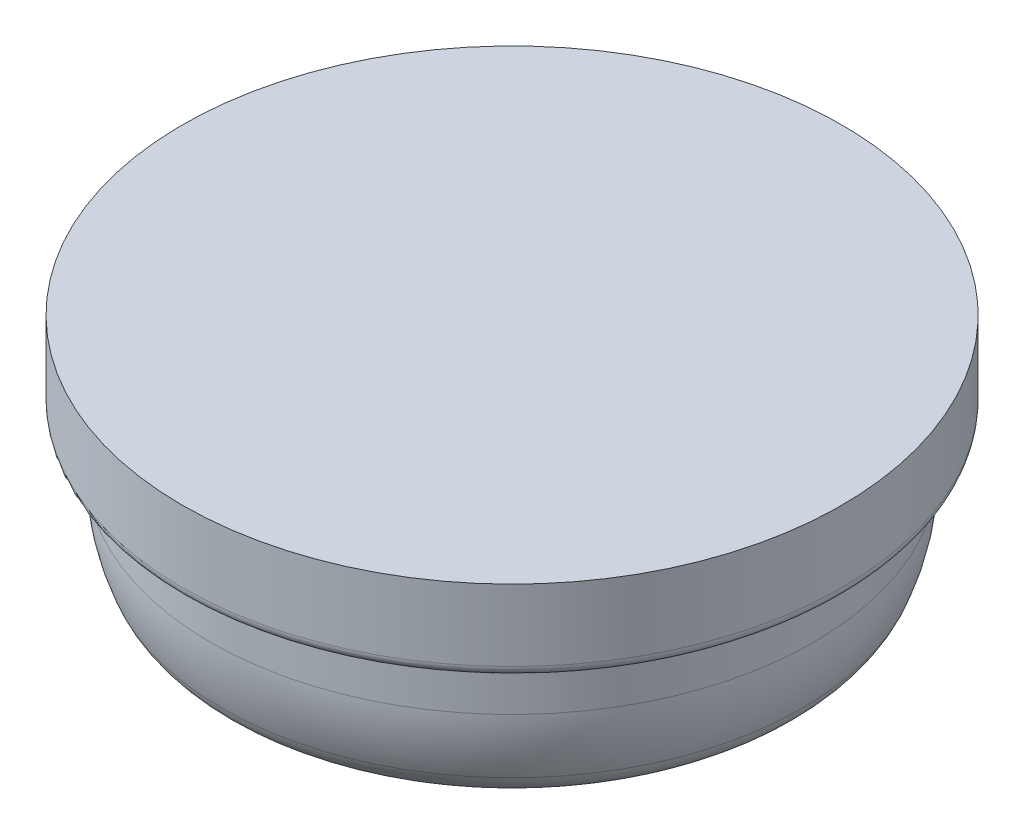
from build123d import *


with BuildPart() as part:
    # Sketch1 → Revolve1 (revolve)
    with BuildSketch(Plane(origin=(0, 0, 0), x_dir=(0, 0, -1), z_dir=(1, 0, 0))):
        with BuildLine():
            Line((-91.186, 13.047291374), (-80.264, 13.047291374))
            Line((-80.264, 13.047291374), (0, 13.047291374))
            Line((0, 13.047291374), (0, 113.365316059))
            Line((0, 113.365316059), (-138.555289406, 113.365316059))
            Line((-138.555289406, 113.365316059), (-138.555289406, 83.365316059))
            ThreePointArc((-138.555289406, 83.365316059), (-137.139237072, 79.987189383), (-133.6675, 78.819291374))
            ThreePointArc((-133.6675, 78.819291374), (-128.772790503, 77.210407188), (-126.6825, 72.501121148))
            Line((-126.6825, 72.501121148), (-126.6825, 57.501121148))
            ThreePointArc((-126.6825, 57.501121148), (-125.408162819, 43.954921466), (-121.629866106, 30.884040279))
            ThreePointArc((-121.629866106, 30.884040279), (-117.916780417, 25.02322781), (-112.298492351, 20.952482505))
            Line((-112.298492351, 20.952482505), (-99.212725253, 14.832128031))
            add(Edge.make_bspline(
                [(-91.186, 13.047291374), (-93.993075649, 13.047291374), (-96.709658085, 13.661416507), (-99.212725253, 14.832128031)],
                knots=[0, 0, 0, 0, 1, 1, 1, 1], degree=3, weights=[0.254333095, 0.254333095, 0.258499794, 0.266833191]))
        make_face()
    revolve(axis=Axis((0, 55, 0), (0, -1, 0)))


solid = part.part
